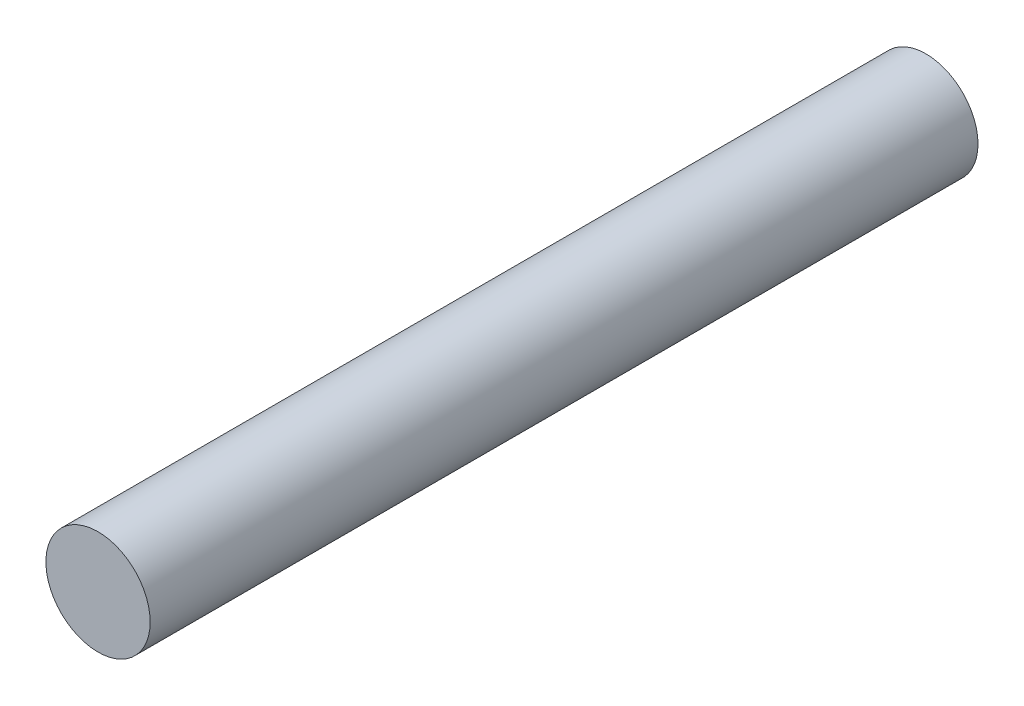
from build123d import *

# Parameters (mm, degrees)
SKETCH2_R           = 1
BOSS_EXTRUDE1_DEPTH = 7.94


with BuildPart() as part:
    # Sketch2 → Boss-Extrude1 (new body, symmetric)
    with BuildSketch(Plane.XY):
        Circle(SKETCH2_R)
    extrude(amount=BOSS_EXTRUDE1_DEPTH, both=True)


solid = part.part
